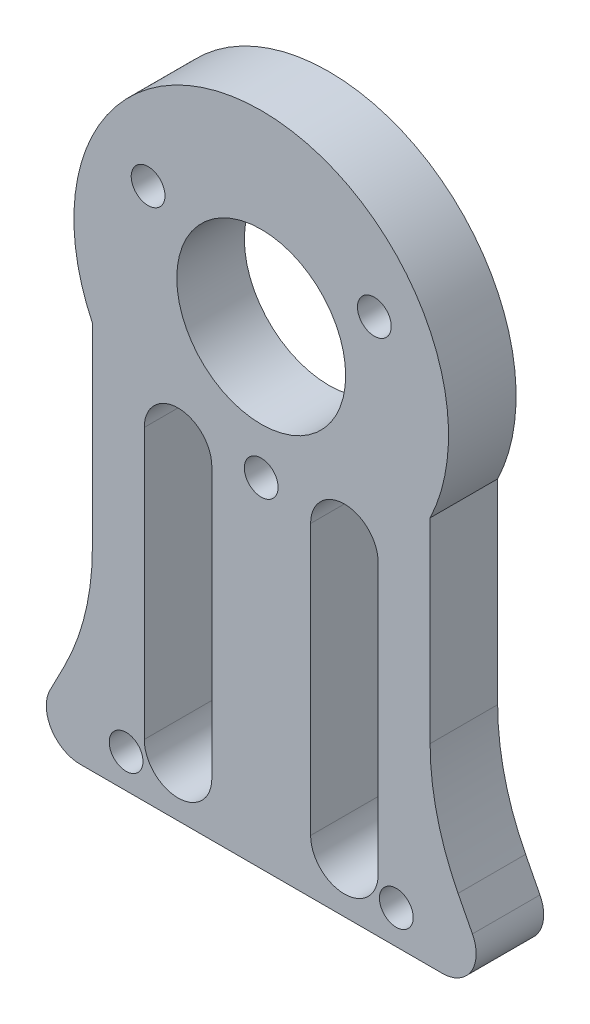
from build123d import *

# Parameters (mm, degrees)
SKETCH2_R           = 1
SKETCH2_R_2         = 5
BOSS_EXTRUDE1_DEPTH = 4


with BuildPart() as part:
    # Sketch2 → Boss-Extrude1 (new body)
    with BuildSketch(Plane.XY):
        with BuildLine():
            Line((10, -4.797958971), (10, -16.375449589))
            ThreePointArc((10, -16.375449589), (10.419623267, -19.898603621), (11.655015244, -23.224637999))
            Line((11.655015244, -23.224637999), (12.504814498, -24.880390098))
            ThreePointArc((12.504814498, -24.880390098), (12.432300446, -26.836100173), (10.725483197, -27.793615219))
            Line((10.725483197, -27.793615219), (-10.725483197, -27.793615219))
            ThreePointArc((-10.725483197, -27.793615219), (-12.432300446, -26.836100173), (-12.504814498, -24.880390098))
            Line((-12.504814498, -24.880390098), (-11.655015244, -23.224637999))
            ThreePointArc((-11.655015244, -23.224637999), (-10.419623267, -19.898603621), (-10, -16.375449589))
            Line((-10, -16.375449589), (-10, -4.797958971))
            ThreePointArc((-10, -4.797958971), (0, 11.091456635), (10, -4.797958971))
        make_face()
        with Locations((-8, -25.793615219)):
            Circle(SKETCH2_R, mode=Mode.SUBTRACT)
        with Locations((8, -25.793615219)):
            Circle(SKETCH2_R, mode=Mode.SUBTRACT)
        Circle(SKETCH2_R_2, mode=Mode.SUBTRACT)
        with Locations((0, -7.733897827)):
            Circle(SKETCH2_R, mode=Mode.SUBTRACT)
        with Locations((-6.697751988, 3.866948913)):
            Circle(SKETCH2_R, mode=Mode.SUBTRACT)
        with Locations((6.697751988, 3.866948913)):
            Circle(SKETCH2_R, mode=Mode.SUBTRACT)
        with BuildLine():
            Line((-2.92427416, -8.622098109), (-2.92427416, -24.622098109))
            ThreePointArc((-2.92427416, -24.622098109), (-4.92427416, -26.622098109), (-6.92427416, -24.622098109))
            Line((-6.92427416, -24.622098109), (-6.92427416, -8.622098109))
            ThreePointArc((-6.92427416, -8.622098109), (-4.92427416, -6.622098109), (-2.92427416, -8.622098109))
        make_face(mode=Mode.SUBTRACT)
        with BuildLine():
            Line((2.92427416, -8.622098109), (2.92427416, -24.622098109))
            ThreePointArc((2.92427416, -24.622098109), (4.92427416, -26.622098109), (6.92427416, -24.622098109))
            Line((6.92427416, -24.622098109), (6.92427416, -8.622098109))
            ThreePointArc((6.92427416, -8.622098109), (4.92427416, -6.622098109), (2.92427416, -8.622098109))
        make_face(mode=Mode.SUBTRACT)
    extrude(amount=BOSS_EXTRUDE1_DEPTH)


solid = part.part
